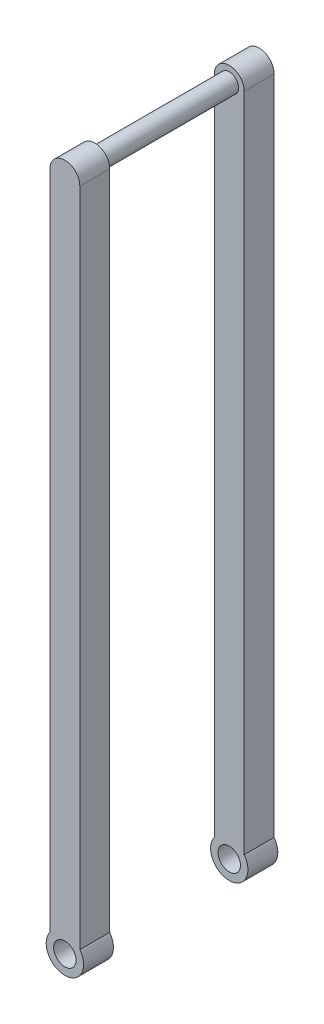
from build123d import *

# Parameters (mm, degrees)
SKETCH1_R                = 1.25
SKETCH1_R_2              = 1.5
BOSS_EXTRUDE1_DEPTH      = 2
BOSS_EXTRUDE1_DEPTH_BACK = 2
SKETCH1_4_R              = 1.25
BOSS_EXTRUDE2_DEPTH      = 20


with BuildPart() as part:
    # Sketch1 → Boss-Extrude1 (new, two sides)
    with BuildSketch(Plane.XY) as boss_extrude1_sk:
        with BuildLine():
            ThreePointArc((2, 1.5), (0, -2.5), (-2, 1.5))
            Line((-2, 1.5), (-2, 90))
            ThreePointArc((-2, 90), (0, 92), (2, 90))
            Line((2, 90), (2, 1.5))
        make_face()
        with Locations((0, 90)):
            Circle(SKETCH1_R, mode=Mode.SUBTRACT)
        Circle(SKETCH1_R_2, mode=Mode.SUBTRACT)
        with Locations((0, 90)):
            Circle(SKETCH1_R)
    extrude(amount=BOSS_EXTRUDE1_DEPTH)
    extrude(boss_extrude1_sk.sketch, amount=-BOSS_EXTRUDE1_DEPTH_BACK)


with BuildPart() as body_2:
    # Mirror2: mirrored copy
    add(part.part.mirror(Plane.XY.offset(11)))


with BuildPart() as part_1:
    add(part.part)

    add(body_2.part)  # Boss-Extrude2 merges body 2
    # Sketch1_4 → Boss-Extrude2 (add)
    with BuildSketch(Plane.XY):
        with Locations(Location((0, 90, 0), (0, 0, 180))):
            Circle(SKETCH1_4_R)
    extrude(amount=BOSS_EXTRUDE2_DEPTH)


solid = part_1.part
